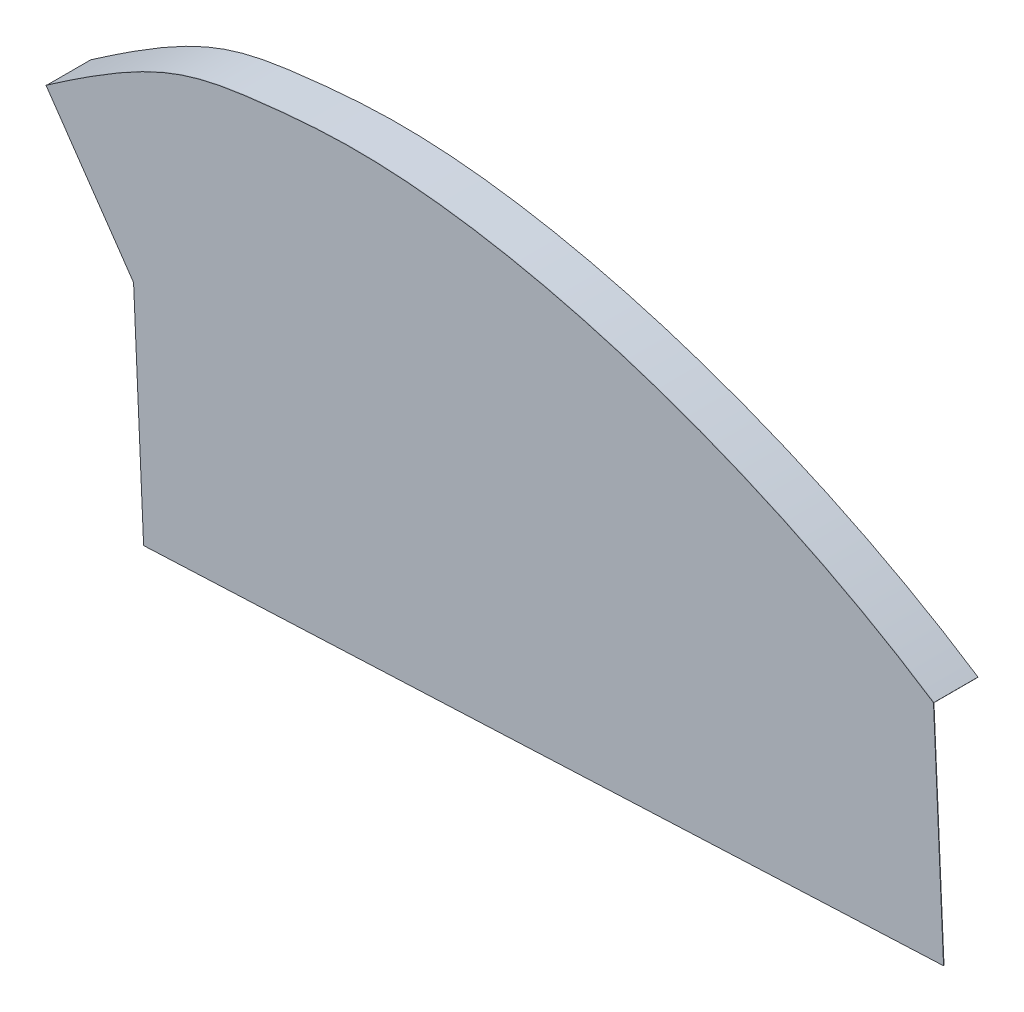
from build123d import *

# Parameters (mm, degrees)
BOSS_EXTRUDE1_DEPTH = 0.1
BOSS_EXTRUDE2_DEPTH = 10


with BuildPart() as part:
    # Sketch1 → Boss-Extrude1 (new body)
    with BuildSketch(Plane.XY):
        with BuildLine():
            Line((-1544.649956659, 573.44143308), (-1542.397344254, 523.492201481))
            Line((-1542.397344254, 523.492201481), (-1721.722963635, 515.404967666))
            Line((-1721.722963635, 515.404967666), (-1723.97557604, 565.354199265))
            Line((-1723.97557604, 565.354199265), (-1743.607960183, 593.830470178))
            add(Edge.make_bspline(
                [(-1743.607960183, 593.830470178), (-1719.507904213, 610.537812828), (-1709.389541143, 613.399774739), (-1646.280289738, 619.241808081), (-1585.716648888, 600.423930323), (-1544.649956659, 573.44143308)],
                knots=[0, 0, 0, 0, 0.320554642, 0.420554642, 1, 1, 1, 1], degree=3))
        make_face()
    extrude(amount=BOSS_EXTRUDE1_DEPTH)

    # Sketch2 → Boss-Extrude2 (add)
    with BuildSketch(Plane.XY.offset(0.1)):
        with BuildLine():
            Line((-1544.677412579, 573.399645851), (-1544.732324417, 573.316071394))
            add(Edge.make_bspline(
                [(-1544.732324417, 573.316071394), (-1546.951948835, 574.774455463), (-1551.43127801, 577.613556033), (-1560.629429442, 583.045346231), (-1572.470935952, 589.326889692), (-1587.069867375, 596.019330748), (-1606.812651261, 603.755089396), (-1626.620904389, 609.625271881), (-1645.785452529, 613.461587482), (-1659.664022733, 615.275078476), (-1672.855430865, 616.000525973), (-1683.17584634, 615.607177853), (-1690.719151522, 614.940047919), (-1697.619410573, 614.184343593), (-1704.94143994, 613.175751133), (-1711.537062872, 611.520585877), (-1716.950731756, 609.496349748), (-1721.226339774, 607.54713974), (-1725.861820037, 605.087085053), (-1730.144377714, 602.544994912), (-1733.894814235, 600.175895508), (-1736.886084267, 598.222624564), (-1739.548362017, 596.435520579), (-1741.775682708, 594.914415574), (-1742.945821332, 594.106977842), (-1743.522500251, 593.707195687)],
                knots=[0, 0, 0, 0, 0.03125, 0.0625, 0.125, 0.1875, 0.25, 0.375, 0.4375, 0.5, 0.5625, 0.625, 0.65625, 0.6875, 0.75, 0.8125, 0.84375, 0.875, 0.90625, 0.9375, 0.953125, 0.96875, 0.984375, 0.9921875, 1, 1, 1, 1], degree=3))
            Line((-1743.522500251, 593.707195687), (-1743.579473539, 593.789378681))
            add(Edge.make_bspline(
                [(-1544.677412579, 573.399645851), (-1580.106306882, 596.677879158), (-1623.417276611, 611.817205851), (-1664.055554326, 615.615316249), (-1668.458587485, 615.853546332), (-1674.850456886, 615.924640206), (-1676.947072346, 615.898899542), (-1681.053950245, 615.760083504), (-1685.070934683, 615.538033819), (-1688.841535286, 615.206941309), (-1692.455660822, 614.85004283), (-1694.182553399, 614.660043123), (-1699.092177305, 614.084892783), (-1702.026740338, 613.678931579), (-1710.391454065, 612.076086015), (-1715.382812403, 610.494610736), (-1727.278520434, 604.6086441), (-1734.182625539, 600.30373531), (-1743.579473539, 593.789378681)],
                knots=[0, 0, 0, 0, 0.5, 0.5, 0.5625, 0.5625, 0.59375, 0.59375, 0.625, 0.65625, 0.65625, 0.6875, 0.6875, 0.75, 0.75, 0.875, 0.875, 1, 1, 1, 1], degree=3))
        make_face()
    extrude(amount=-BOSS_EXTRUDE2_DEPTH)


solid = part.part
